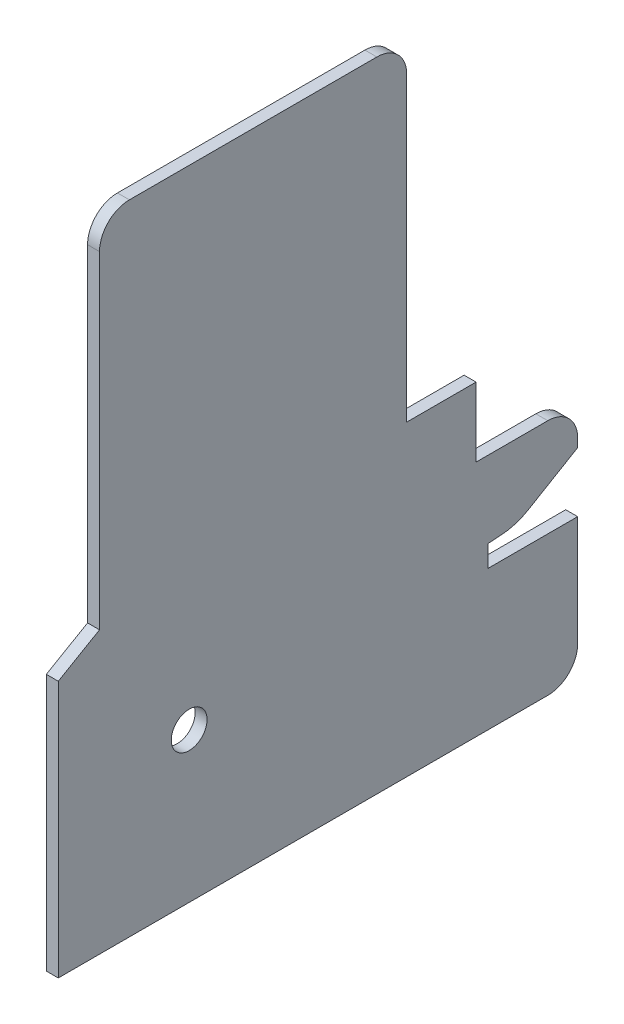
from build123d import *

# Parameters (mm, degrees)
AUFSATZ_LINEAR_AUSTRAGEN1_DEPTH = 2
VERRUNDUNG6_R                   = 5
VERRUNDUNG7_R                   = 10
SKIZZE4_R                       = 3
SCHNITT_LINEAR_AUSTRAGEN1_DEPTH = 2


with BuildPart() as part:
    # Skizze2 → Aufsatz-Linear austragen1 (new body)
    with BuildSketch(Plane(origin=(0, 0, 0), x_dir=(0, 0, -1), z_dir=(1, 0, 0))):
        Polygon((0, 0), (-86.9, 0), (-86.9, 43), (-80, 47), (-80, 106.8), (-28.6, 106.8), (-28.6, 51.396087758), (-17, 51.396087758), (-17, 39.8), (0, 39.8), (0, 33.4), (-10.333924714, 27.3), (-15, 27), (-15, 23.4), (0, 23.4), align=None)
    extrude(amount=-AUFSATZ_LINEAR_AUSTRAGEN1_DEPTH)

    # Verrundung6
    verrundung6_edges = [part.edges().sort_by_distance(p)[0] for p in [
        (-1, 0, 0),
        (-1, 106.8, 80),
        (-1, 106.8, 28.6),
        (-1, 39.8, 0),
    ]]
    fillet(verrundung6_edges, radius=VERRUNDUNG6_R)

    # Verrundung7
    verrundung7_edges = [part.edges().sort_by_distance(p)[0] for p in [
        (-1, 27.3, 10.333924714),
    ]]
    fillet(verrundung7_edges, radius=VERRUNDUNG7_R)

    # Skizze4 → Schnitt-Linear austragen1 (cut)
    with BuildSketch(Plane(origin=(0, 0, 0), x_dir=(0, 0, -1), z_dir=(1, 0, 0))):
        with Locations((-65, 25)):
            Circle(SKIZZE4_R)
    extrude(amount=-SCHNITT_LINEAR_AUSTRAGEN1_DEPTH, mode=Mode.SUBTRACT)


solid = part.part
